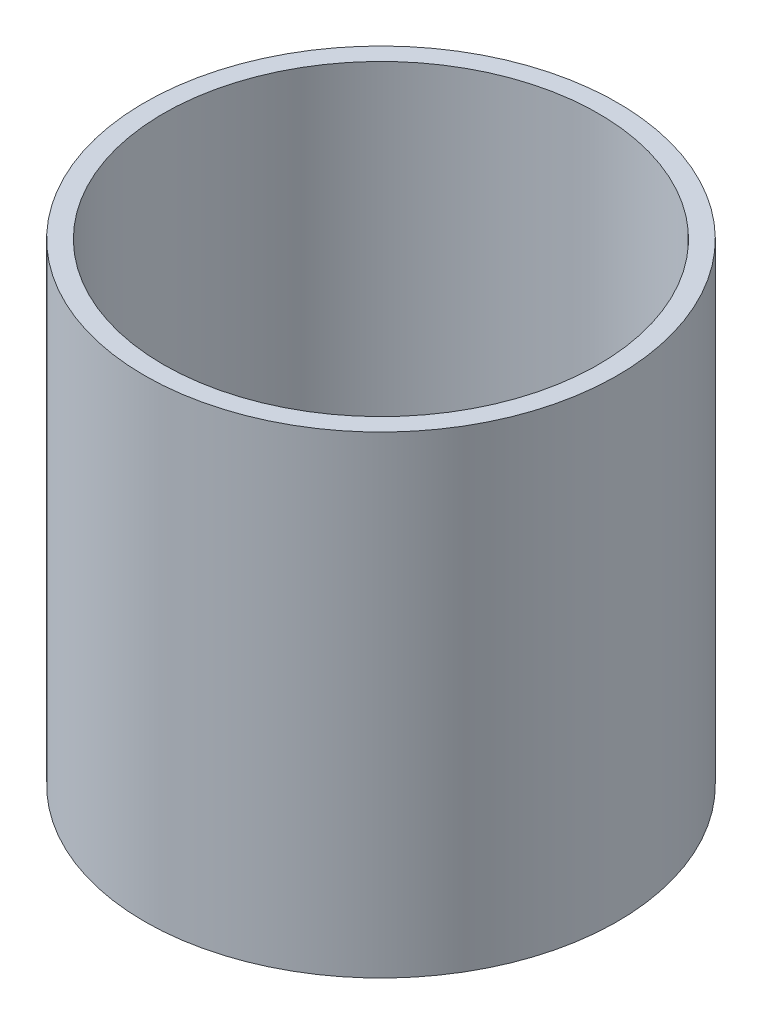
from build123d import *

# Parameters (mm, degrees)
SKETCH1_R           = 3.175
SKETCH1_R_2         = 2.921
BOSS_EXTRUDE1_DEPTH = 6.35


with BuildPart() as part:
    # Sketch1 → Boss-Extrude1 (new body)
    with BuildSketch(Plane(origin=(0, 0, 0), x_dir=(1, 0, 0), z_dir=(0, 1, 0))):
        Circle(SKETCH1_R)
        Circle(SKETCH1_R_2, mode=Mode.SUBTRACT)
    extrude(amount=BOSS_EXTRUDE1_DEPTH)


solid = part.part
